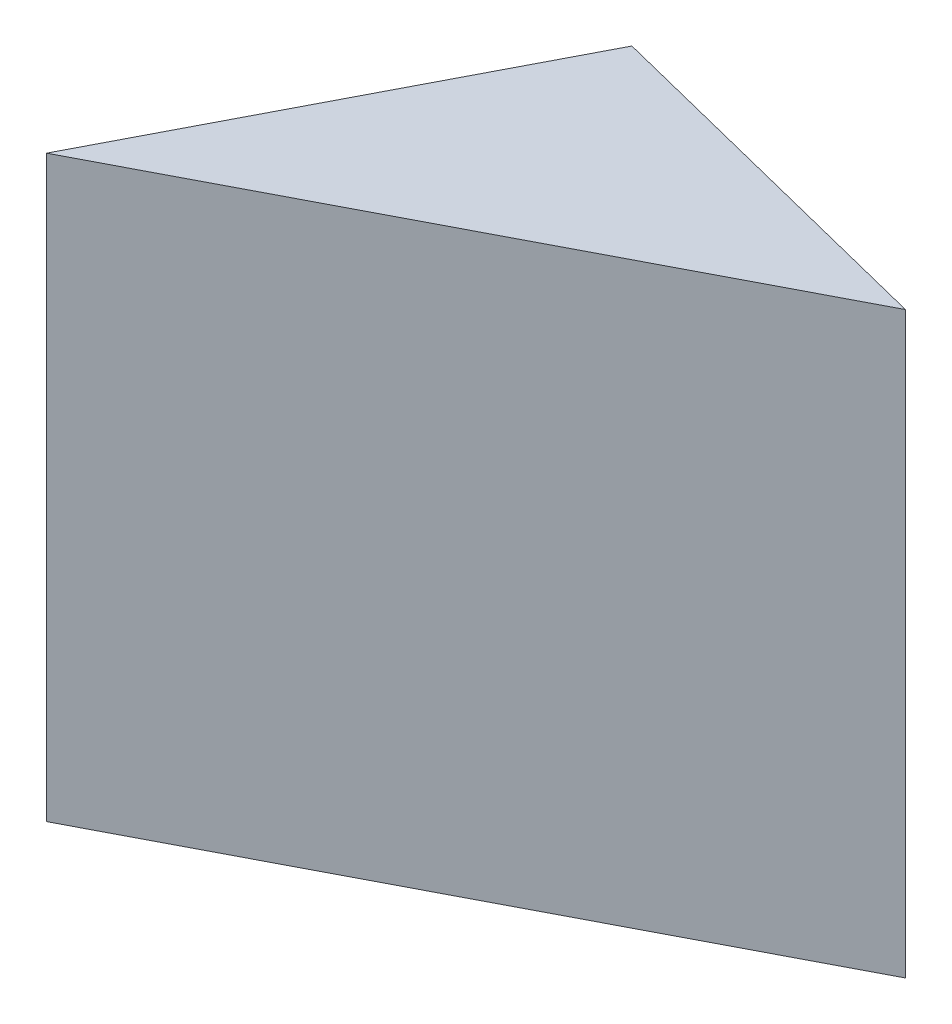
from build123d import *

# Parameters (mm, degrees)
EXTRUDE1_DEPTH = 20


with BuildPart() as part:
    # Sketch1 → Extrude1 (new body)
    with BuildSketch(Plane(origin=(0, 0, 0), x_dir=(1, 0, 0), z_dir=(0, 1, 0))):
        Polygon((0, 0), (6.904617299, 13.316390651), (19.514907337, 10.157184238), align=None)
    extrude(amount=EXTRUDE1_DEPTH)


solid = part.part
